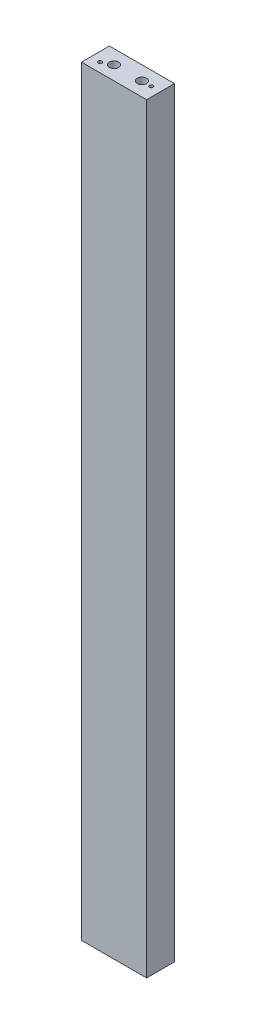
from build123d import *

# Parameters (mm, degrees)
SKETCH1_W                                  = 88.9
SKETCH1_H                                  = 38.1
BOSS_EXTRUDE1_DEPTH                        = 1038.225
SKETCH2_R                                  = 6.35
CUT_EXTRUDE1_DEPTH                         = 19.05
SKETCH3_R                                  = 6.35
CUT_EXTRUDE2_DEPTH                         = 19.05
F_10_0_1935_DIAMETER_HOLE1_D               = 4.9149
F_10_0_1935_DIAMETER_HOLE1_DEPTH           = 76.2
F_10_0_1935_DIAMETER_HOLE1_TIP             = 1.476584928
F_10_0_1935_DIAMETER_HOLE1_ON_FACE_2_D     = 4.9149
F_10_0_1935_DIAMETER_HOLE1_ON_FACE_2_DEPTH = 76.2
F_10_0_1935_DIAMETER_HOLE1_ON_FACE_2_TIP   = 1.476584928


with BuildPart() as part:
    # Sketch1 → Boss-Extrude1 (new body)
    with BuildSketch(Plane(origin=(0, 0, 0), x_dir=(1, 0, 0), z_dir=(0, 1, 0))):
        with Locations((44.45, -19.05)):
            Rectangle(SKETCH1_W, SKETCH1_H)
    extrude(amount=BOSS_EXTRUDE1_DEPTH)

    # Sketch2 → Cut-Extrude1 (cut)
    with BuildSketch(Plane(origin=(0, 1038.225, 0), x_dir=(1, 0, 0), z_dir=(0, 1, 0))):
        with Locations((25.4, -19.05)):
            Circle(SKETCH2_R)
        with Locations((63.5, -19.05)):
            Circle(SKETCH2_R)
    extrude(amount=-CUT_EXTRUDE1_DEPTH, mode=Mode.SUBTRACT)

    # Sketch3 → Cut-Extrude2 (cut)
    with BuildSketch(Plane.XZ):
        with Locations((25.4, 19.05)):
            Circle(SKETCH3_R)
        with Locations((63.5, 19.05)):
            Circle(SKETCH3_R)
    extrude(amount=-CUT_EXTRUDE2_DEPTH, mode=Mode.SUBTRACT)

    # #10 (0.1935) Diameter Hole1
    with Locations(Plane(origin=(44.45, 0, 25.4), x_dir=(0, 0, -1), z_dir=(0, -1, 0))):
        with Locations((0, 0)):
            Hole(F_10_0_1935_DIAMETER_HOLE1_D / 2, depth=F_10_0_1935_DIAMETER_HOLE1_DEPTH)
            with Locations((0, 0, -(F_10_0_1935_DIAMETER_HOLE1_DEPTH + F_10_0_1935_DIAMETER_HOLE1_TIP / 2))):  # 118° drill point
                Cone(0, F_10_0_1935_DIAMETER_HOLE1_D / 2, F_10_0_1935_DIAMETER_HOLE1_TIP, mode=Mode.SUBTRACT)

    # #10 (0.1935) Diameter Hole1 on face 2
    with Locations(Plane(origin=(12.7, 1038.225, 25.4), x_dir=(0, 0, 1), z_dir=(0, 1, 0))):
        with Locations((0, 0), (-6.35, 63.5)):
            Hole(F_10_0_1935_DIAMETER_HOLE1_ON_FACE_2_D / 2, depth=F_10_0_1935_DIAMETER_HOLE1_ON_FACE_2_DEPTH)
            with Locations((0, 0, -(F_10_0_1935_DIAMETER_HOLE1_ON_FACE_2_DEPTH + F_10_0_1935_DIAMETER_HOLE1_ON_FACE_2_TIP / 2))):  # 118° drill point
                Cone(0, F_10_0_1935_DIAMETER_HOLE1_ON_FACE_2_D / 2, F_10_0_1935_DIAMETER_HOLE1_ON_FACE_2_TIP, mode=Mode.SUBTRACT)


solid = part.part
